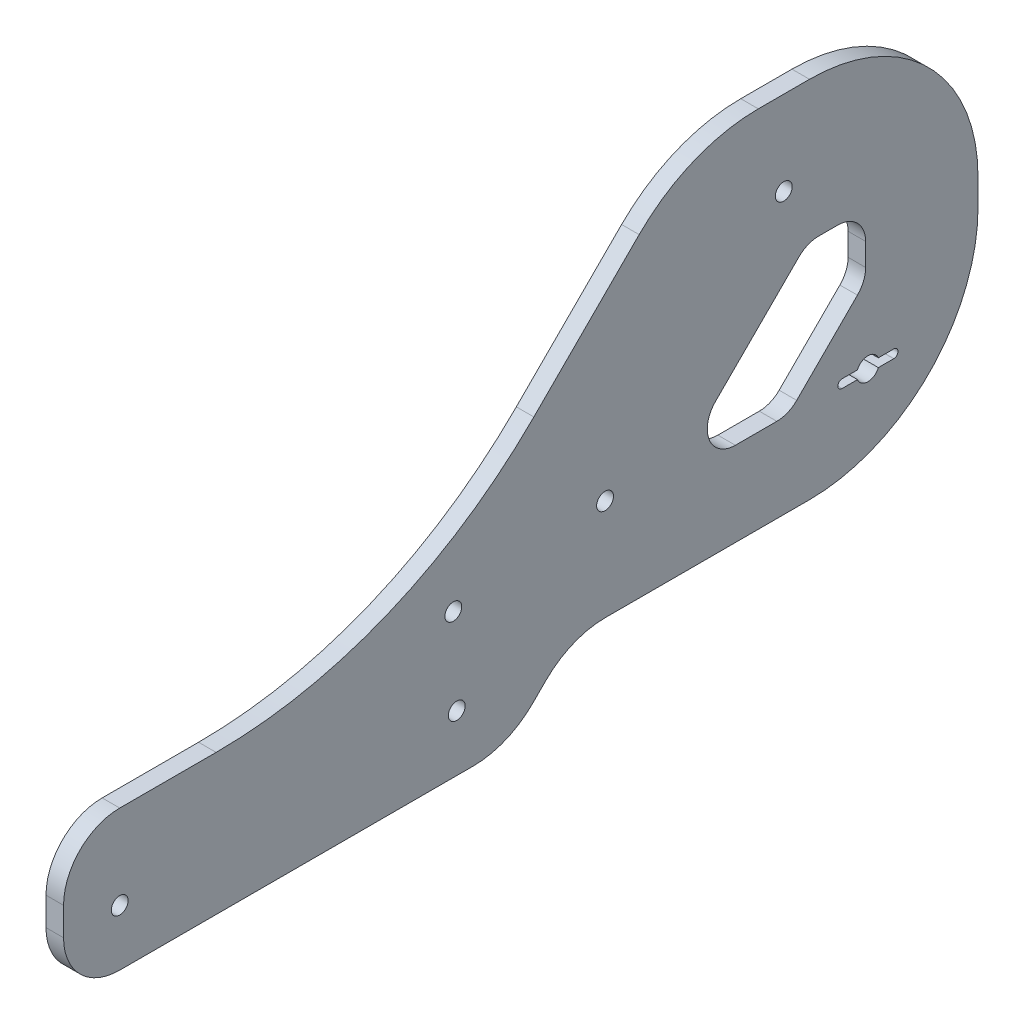
from build123d import *

# Parameters (mm, degrees)
SKETCH1_R           = 1.5
BOSS_EXTRUDE1_DEPTH = 3.125
FILLET1_R           = 10
FILLET2_R           = 15
FILLET3_R           = 30
FILLET4_R           = 30
FILLET5_R           = 80
FILLET6_R           = 30
FILLET7_R           = 5


with BuildPart() as part:
    # Sketch1 → Boss-Extrude1 (new body)
    with BuildSketch(Plane(origin=(0, 0, 0), x_dir=(0, 0, -1), z_dir=(1, 0, 0))):
        Polygon((-143.20422433, -1.13137085), (-143.20422433, -26.13137085), (-64.062088707, -26.13137085), (-52.930717857, -15), (19.6, -15), (19.6, 49.830569927), (-31.940768363, 49.830569927), (-82.90270914, -1.13137085), align=None)
        with Locations((-46.799347007, 3.010764774)):
            Circle(SKETCH1_R, mode=Mode.SUBTRACT)
        with Locations((-14.979541854, 34.830569927)):
            Circle(SKETCH1_R, mode=Mode.SUBTRACT)
        with Locations((-73.810826048, -0.524769132)):
            Circle(SKETCH1_R, mode=Mode.SUBTRACT)
        with Locations((-73.20422433, -16.13137085)):
            Circle(SKETCH1_R, mode=Mode.SUBTRACT)
        with Locations((-133.20422433, -16.13137085)):
            Circle(SKETCH1_R, mode=Mode.SUBTRACT)
        with BuildLine():
            Line((-4.6, 0.75), (-1.854049622, 0.75))
            ThreePointArc((-1.854049622, 0.75), (0, 2), (1.854049622, 0.75))
            Line((1.854049622, 0.75), (4.6, 0.75))
            ThreePointArc((4.6, 0.75), (5.35, 0), (4.6, -0.75))
            Line((4.6, -0.75), (1.854049622, -0.75))
            ThreePointArc((1.854049622, -0.75), (0, -2), (-1.854049622, -0.75))
            Line((-1.854049622, -0.75), (-4.6, -0.75))
            ThreePointArc((-4.6, -0.75), (-5.35, 0), (-4.6, 0.75))
        make_face(mode=Mode.SUBTRACT)
        Polygon((-35.667976157, 0), (-10.83740623, 24.830569927), (-0.4, 24.830569927), (-0.4, 13.742135624), (-14.142135624, 0), align=None, mode=Mode.SUBTRACT)
    extrude(amount=BOSS_EXTRUDE1_DEPTH)

    # Fillet1
    fillet1_edges = [part.edges().sort_by_distance(p)[0] for p in [
        (1.5625, -26.13137085, 143.20422433),
        (1.5625, -1.13137085, 143.20422433),
    ]]
    fillet(fillet1_edges, radius=FILLET1_R)

    # Fillet2
    fillet2_edges = [part.edges().sort_by_distance(p)[0] for p in [
        (1.5625, -15, 52.930717857),
        (1.5625, -26.13137085, 64.062088707),
    ]]
    fillet(fillet2_edges, radius=FILLET2_R)

    # Fillet3
    fillet3_edges = [part.edges().sort_by_distance(p)[0] for p in [
        (1.5625, -15, -19.6),
    ]]
    fillet(fillet3_edges, radius=FILLET3_R)

    # Fillet4
    fillet4_edges = [part.edges().sort_by_distance(p)[0] for p in [
        (1.5625, 49.830569927, 31.940768363),
    ]]
    fillet(fillet4_edges, radius=FILLET4_R)

    # Fillet5
    fillet5_edges = [part.edges().sort_by_distance(p)[0] for p in [
        (1.5625, -1.13137085, 82.90270914),
    ]]
    fillet(fillet5_edges, radius=FILLET5_R)

    # Fillet6
    fillet6_edges = [part.edges().sort_by_distance(p)[0] for p in [
        (1.5625, 49.830569927, -19.6),
    ]]
    fillet(fillet6_edges, radius=FILLET6_R)

    # Fillet7
    fillet7_edges = [part.edges().sort_by_distance(p)[0] for p in [
        (1.5625, 13.742135624, 0.4),
        (1.5625, 24.830569927, 0.4),
        (1.5625, 24.830569927, 10.83740623),
        (1.5625, 0, 35.667976157),
        (1.5625, 0, 14.142135624),
    ]]
    fillet(fillet7_edges, radius=FILLET7_R)


solid = part.part
